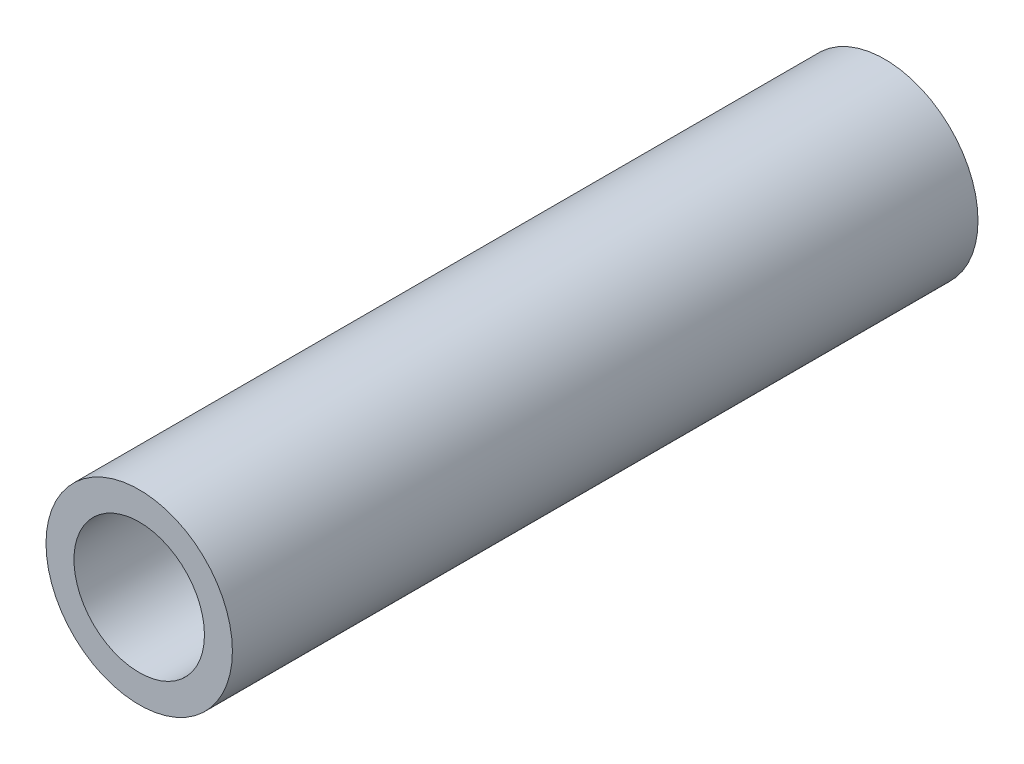
from build123d import *

# Parameters (mm, degrees)
SKETCH1_R      = 1.5
SKETCH1_R_2    = 1.05
EXTRUDE1_DEPTH = 12


with BuildPart() as part:
    # Sketch1 → Extrude1 (new body)
    with BuildSketch(Plane.XY):
        Circle(SKETCH1_R)
        Circle(SKETCH1_R_2, mode=Mode.SUBTRACT)
    extrude(amount=EXTRUDE1_DEPTH)


solid = part.part
